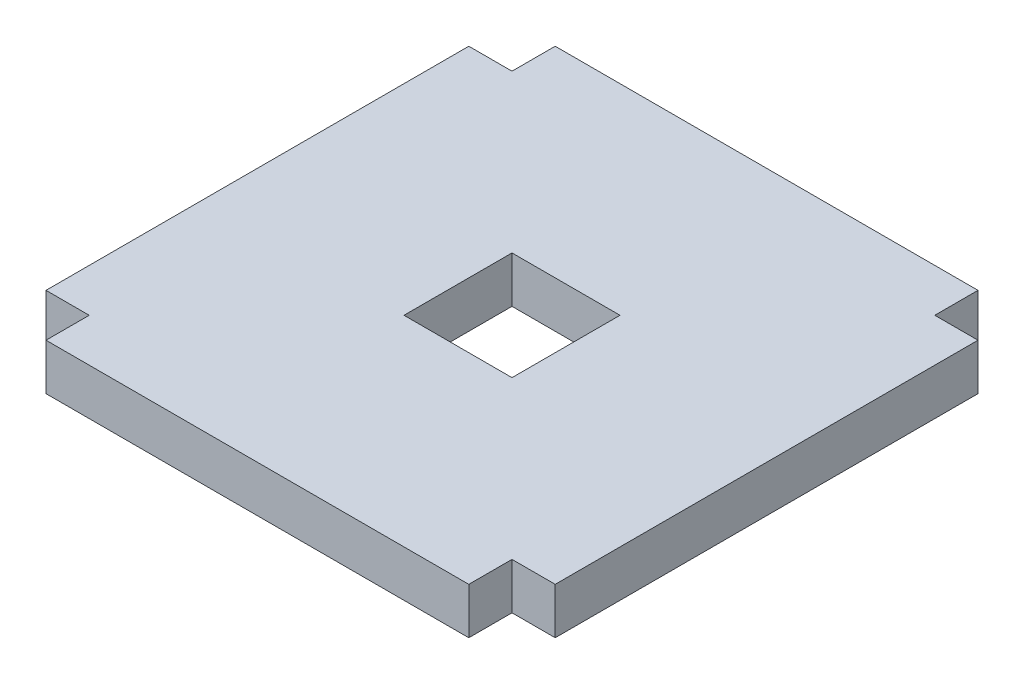
from build123d import *

# Parameters (mm, degrees)
SKETCH1_W           = 44.45
SKETCH1_H           = 44.45
BOSS_EXTRUDE1_DEPTH = 19.05


with BuildPart() as part:
    # Sketch1 → Boss-Extrude1 (new body)
    with BuildSketch(Plane(origin=(0, 0, 0), x_dir=(1, 0, 0), z_dir=(0, 1, 0))):
        Polygon((-86.995, 86.995), (-104.775, 86.995), (-104.775, -86.995), (-86.995, -86.995), (-86.995, -104.775), (86.995, -104.775), (86.995, -86.995), (104.775, -86.995), (104.775, 86.995), (86.995, 86.995), (86.995, 104.775), (-86.995, 104.775), align=None)
        Rectangle(SKETCH1_W, SKETCH1_H, mode=Mode.SUBTRACT)
    extrude(amount=BOSS_EXTRUDE1_DEPTH)


solid = part.part
